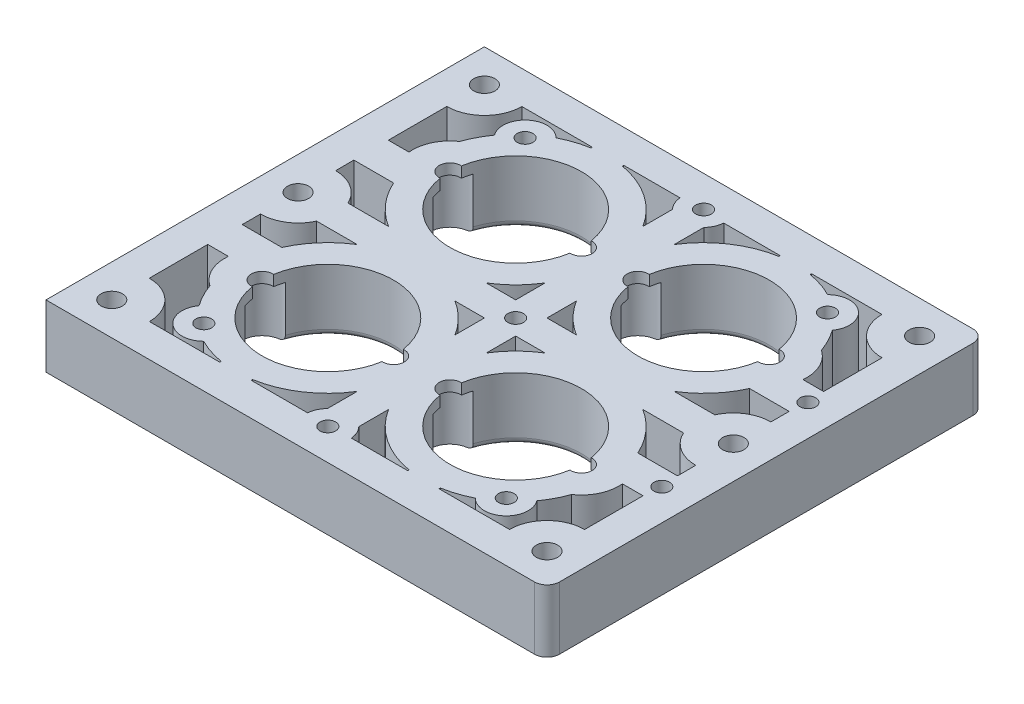
from build123d import *

# Parameters (mm, degrees)
SKETCH1_W                       = 80
SKETCH1_H                       = 70
BOSS_EXTRUDE1_DEPTH             = 10
CUT_EXTRUDE2_REACH              = 12
SKETCH3_R                       = 10.5
M3X0_5_TAPPED_HOLE1_D           = 2.5
M3X0_5_TAPPED_HOLE1_DEPTH       = 10
CBORE_FOR_M3_SHCS1_D            = 3.4
CBORE_FOR_M3_SHCS1_DEPTH        = 10
CBORE_FOR_M3_SHCS1_CBORE_D      = 6.5
CBORE_FOR_M3_SHCS1_CBORE_DEPTH  = 6
FILLET3_R                       = 1
TAP_DRILL_FOR_M3X0_5_TAP1_D     = 2.5
TAP_DRILL_FOR_M3X0_5_TAP1_DEPTH = 10
TAP_DRILL_FOR_M3X0_5_TAP1_TIP   = 0.751075774
FILLET4_R                       = 2
CBORE_FOR_M3_SHCS2_D            = 3.4
CBORE_FOR_M3_SHCS2_CBORE_D      = 6.5
CBORE_FOR_M3_SHCS2_CBORE_DEPTH  = 8.3
TAP_DRILL_FOR_M3X0_5_TAP2_D     = 2.5
TAP_DRILL_FOR_M3X0_5_TAP2_DEPTH = 10
CUT_EXTRUDE3_DEPTH              = 10


with BuildPart() as part:
    # Sketch1 → Boss-Extrude1 (new body)
    with BuildSketch(Plane(origin=(0, 0, 0), x_dir=(1, 0, 0), z_dir=(0, 1, 0))):
        with Locations((-2.631253278, 2.602774632)):
            Rectangle(SKETCH1_W, SKETCH1_H)
    extrude(amount=BOSS_EXTRUDE1_DEPTH)

    # Sketch3 → Cut-Extrude2 (cut, up to next)
    with BuildSketch(Plane(origin=(0, 10, 0), x_dir=(-1, 0, 0), z_dir=(0, 1, 0)), mode=Mode.PRIVATE) as cut_extrude2_sk1:
        with Locations(Location((17.631253278, -17.602774632, 0), (0, 0, 90))):  # turned: the seam where the file's is
            Circle(SKETCH3_R)
    cut_extrude2_tool1 = extrude(cut_extrude2_sk1.sketch, amount=-CUT_EXTRUDE2_REACH, mode=Mode.PRIVATE) & part.part
    add(cut_extrude2_tool1.solids().sort_by_distance((-17.631253, 10, -17.602775))[0], mode=Mode.SUBTRACT)
    # Sketch3 → Cut-Extrude2 (cut, up to next)
    with BuildSketch(Plane(origin=(0, 10, 0), x_dir=(-1, 0, 0), z_dir=(0, 1, 0)), mode=Mode.PRIVATE) as cut_extrude2_sk2:
        with Locations(Location((-12.368746722, -17.602774632, 0), (0, 0, 90))):  # turned: the seam where the file's is
            Circle(SKETCH3_R)
    cut_extrude2_tool2 = extrude(cut_extrude2_sk2.sketch, amount=-CUT_EXTRUDE2_REACH, mode=Mode.PRIVATE) & part.part
    add(cut_extrude2_tool2.solids().sort_by_distance((12.368747, 10, -17.602775))[0], mode=Mode.SUBTRACT)
    # Sketch3 → Cut-Extrude2 (cut, up to next)
    with BuildSketch(Plane(origin=(0, 10, 0), x_dir=(-1, 0, 0), z_dir=(0, 1, 0)), mode=Mode.PRIVATE) as cut_extrude2_sk3:
        with Locations(Location((17.631253278, 12.397225368, 0), (0, 0, 90))):  # turned: the seam where the file's is
            Circle(SKETCH3_R)
    cut_extrude2_tool3 = extrude(cut_extrude2_sk3.sketch, amount=-CUT_EXTRUDE2_REACH, mode=Mode.PRIVATE) & part.part
    add(cut_extrude2_tool3.solids().sort_by_distance((-17.631253, 10, 12.397225))[0], mode=Mode.SUBTRACT)
    # Sketch3 → Cut-Extrude2 (cut, up to next)
    with BuildSketch(Plane(origin=(0, 10, 0), x_dir=(-1, 0, 0), z_dir=(0, 1, 0)), mode=Mode.PRIVATE) as cut_extrude2_sk4:
        with Locations(Location((-12.368746722, 12.397225368, 0), (0, 0, 90))):  # turned: the seam where the file's is
            Circle(SKETCH3_R)
    cut_extrude2_tool4 = extrude(cut_extrude2_sk4.sketch, amount=-CUT_EXTRUDE2_REACH, mode=Mode.PRIVATE) & part.part
    add(cut_extrude2_tool4.solids().sort_by_distance((12.368747, 10, 12.397225))[0], mode=Mode.SUBTRACT)

    # M3x0.5 Tapped Hole1
    with Locations(Plane(origin=(-26.781253278, 10, 23.047225368), x_dir=(0, 0, 1), z_dir=(0, 1, 0))):
        with Locations((0, 0), (-51.3, 0), (-51.3, 48.3), (0, 48.3)):
            Hole(M3X0_5_TAPPED_HOLE1_D / 2, depth=M3X0_5_TAPPED_HOLE1_DEPTH)

    # CBORE for M3 SHCS1
    with Locations(Plane(origin=(-37.381253278, 0, 27.147225368), x_dir=(0, 0, -1), z_dir=(0, -1, 0))):
        with Locations((0, 0), (29.75, 0), (59.5, 0), (0, 69.5), (29.75, 69.5), (59.5, 69.5)):
            CounterBoreHole(CBORE_FOR_M3_SHCS1_D / 2, CBORE_FOR_M3_SHCS1_CBORE_D / 2, CBORE_FOR_M3_SHCS1_CBORE_DEPTH, depth=CBORE_FOR_M3_SHCS1_DEPTH)

    # Fillet3
    fillet3_edges = [part.edges().sort_by_distance(p)[0] for p in [
        (-17.631253278, 0, -28.102774632),
        (12.368746722, 0, -28.102774632),
        (-17.631253278, 0, 1.897225368),
        (12.368746722, 0, 1.897225368),
    ]]
    fillet(fillet3_edges, radius=FILLET3_R)

    # Tap Drill for M3x0.5 Tap1
    with Locations(Plane(origin=(-42.631253278, 5, 9.063892035), x_dir=(0, 0, -1), z_dir=(-1, 0, 0))):
        with Locations((0, 0), (23.333333334, 0)):
            Hole(TAP_DRILL_FOR_M3X0_5_TAP1_D / 2, depth=TAP_DRILL_FOR_M3X0_5_TAP1_DEPTH)
            with Locations((0, 0, -(TAP_DRILL_FOR_M3X0_5_TAP1_DEPTH + TAP_DRILL_FOR_M3X0_5_TAP1_TIP / 2))):  # 118° drill point
                Cone(0, TAP_DRILL_FOR_M3X0_5_TAP1_D / 2, TAP_DRILL_FOR_M3X0_5_TAP1_TIP, mode=Mode.SUBTRACT)

    # Fillet4
    fillet4_edges = [part.edges().sort_by_distance(p)[0] for p in [
        (37.368746722, 5, -37.602774632),
        (37.368746722, 5, 32.397225368),
    ]]
    fillet(fillet4_edges, radius=FILLET4_R)

    # CBORE for M3 SHCS2 (through all)
    with Locations(Plane(origin=(-28.131253278, 0, 12.397225368), x_dir=(0, 0, -1), z_dir=(0, -1, 0))):
        with Locations((0, 0), (0, 30), (0, 21), (0, 51), (30, 0), (30, 21), (30, 30), (30, 51)):
            CounterBoreHole(CBORE_FOR_M3_SHCS2_D / 2, CBORE_FOR_M3_SHCS2_CBORE_D / 2, CBORE_FOR_M3_SHCS2_CBORE_DEPTH)

    # Tap Drill for M3x0.5 Tap2
    with Locations(Plane(origin=(-2.631253278, 0, 27.397225368), x_dir=(0, 0, -1), z_dir=(0, -1, 0))):
        with Locations((0, 0), (30, 0), (60, 0), (41.666666667, 35), (18.333333333, 35)):
            Hole(TAP_DRILL_FOR_M3X0_5_TAP2_D / 2, depth=TAP_DRILL_FOR_M3X0_5_TAP2_DEPTH)

    # Sketch21 → Cut-Extrude3 (cut)
    with BuildSketch(Plane.XZ):
        with BuildLine():
            Line((-20.131253278, 27.133547896), (-31.381268867, 27.133547896))
            ThreePointArc((-31.381268867, 27.133547896), (-33.145530443, 22.89767809), (-37.387126516, 21.147228243))
            Line((-37.387126516, 21.147228243), (-37.387126516, 11.813892035))
            Line((-37.387126516, 11.813892035), (-34.091707756, 11.813892035))
            ThreePointArc((-34.091707756, 11.813892035), (-33.558684155, 14.929080308), (-31.514201196, 17.339184367))
            ThreePointArc((-31.514201196, 17.339184367), (-30.688791614, 19.22803017), (-29.607892074, 20.983221221))
            ThreePointArc((-29.607892074, 20.983221221), (-29.06210081, 25.701982332), (-24.314970793, 25.530660631))
            ThreePointArc((-24.314970793, 25.530660631), (-23.145728323, 26.062867198), (-21.934576811, 26.491217287))
            ThreePointArc((-21.934576811, 26.491217287), (-21.039662479, 26.733959597), (-20.131253278, 26.91993867))
            Line((-20.131253278, 26.91993867), (-20.131253278, 27.133547896))
        make_face()
        with BuildLine():
            Line((-15.131253278, 27.133547896), (-15.131253278, 26.91993867))
            ThreePointArc((-15.131253278, 26.91993867), (-9.413357154, 24.629370926), (-5.131253278, 20.20166011))
            Line((-5.131253278, 20.20166011), (-5.131253278, 24.947735625))
            ThreePointArc((-5.131253278, 24.947735625), (-5.819454868, 25.95314413), (-6.121306886, 27.133547896))
            Line((-6.121306886, 27.133547896), (-15.131253278, 27.133547896))
        make_face()
        with BuildLine():
            ThreePointArc((-31.053334234, 6.313892035), (-28.71884296, 2.690291934), (-25.43568802, -0.102774632))
            Line((-25.43568802, -0.102774632), (-31.92689722, -0.102774632))
            ThreePointArc((-31.92689722, -0.102774632), (-34.140882929, 2.446977837), (-37.381253278, 3.397225368))
            Line((-37.381253278, 3.397225368), (-37.387126516, 6.313892035))
            Line((-37.387126516, 6.313892035), (-31.053334234, 6.313892035))
        make_face()
        with BuildLine():
            Line((-31.92689722, -5.102774632), (-25.43568802, -5.102774632))
            ThreePointArc((-25.43568802, -5.102774632), (-28.71884296, -7.895841198), (-31.053334234, -11.519441299))
            Line((-31.053334234, -11.519441299), (-37.387126516, -11.519441299))
            Line((-37.387126516, -11.519441299), (-37.381253278, -8.602774632))
            ThreePointArc((-37.381253278, -8.602774632), (-34.140882929, -7.652527101), (-31.92689722, -5.102774632))
        make_face()
        with BuildLine():
            Line((-37.387126516, -26.352777507), (-37.387126516, -17.019441299))
            Line((-37.387126516, -17.019441299), (-34.091707756, -17.019441299))
            ThreePointArc((-34.091707756, -17.019441299), (-33.558684155, -20.134629572), (-31.514201196, -22.544733631))
            ThreePointArc((-31.514201196, -22.544733631), (-30.688791614, -24.433579434), (-29.607892074, -26.188770485))
            ThreePointArc((-29.607892074, -26.188770485), (-29.06210081, -30.907531595), (-24.314970793, -30.736209895))
            ThreePointArc((-24.314970793, -30.736209895), (-22.275356013, -31.588178145), (-20.131253278, -32.125487934))
            Line((-20.131253278, -32.125487934), (-20.131253278, -32.33909716))
            Line((-20.131253278, -32.33909716), (-31.381268867, -32.33909716))
            ThreePointArc((-31.381268867, -32.33909716), (-33.145530443, -28.103227354), (-37.387126516, -26.352777507))
        make_face()
        with BuildLine():
            Line((-15.131253278, -32.33909716), (-6.121306886, -32.33909716))
            ThreePointArc((-6.121306886, -32.33909716), (-5.819454868, -31.158693394), (-5.131253278, -30.153284889))
            Line((-5.131253278, -30.153284889), (-5.131253278, -25.407209374))
            ThreePointArc((-5.131253278, -25.407209374), (-9.413357154, -29.834920189), (-15.131253278, -32.125487934))
            Line((-15.131253278, -32.125487934), (-15.131253278, -32.33909716))
        make_face()
        with BuildLine():
            Line((-9.826818536, -5.102774632), (-5.131253278, -5.102774632))
            Line((-5.131253278, -5.102774632), (-5.131253278, -9.79833989))
            ThreePointArc((-5.131253278, -9.79833989), (-7.211099689, -7.182621043), (-9.826818536, -5.102774632))
        make_face()
        with BuildLine():
            ThreePointArc((-9.826818536, -0.102774632), (-7.211099689, 1.977071779), (-5.131253278, 4.592790626))
            Line((-5.131253278, 4.592790626), (-5.131253278, -0.102774632))
            Line((-5.131253278, -0.102774632), (-9.826818536, -0.102774632))
        make_face()
        with BuildLine():
            Line((4.56431198, -0.102774632), (-0.131253278, -0.102774632))
            Line((-0.131253278, -0.102774632), (-0.131253278, 4.592790626))
            ThreePointArc((-0.131253278, 4.592790626), (1.948593133, 1.977071779), (4.56431198, -0.102774632))
        make_face()
        with BuildLine():
            ThreePointArc((4.56431198, -5.102774632), (1.948593133, -7.182621043), (-0.131253278, -9.79833989))
            Line((-0.131253278, -9.79833989), (-0.131253278, -5.102774632))
            Line((-0.131253278, -5.102774632), (4.56431198, -5.102774632))
        make_face()
        with BuildLine():
            Line((9.868746722, -32.33909716), (9.868746722, -32.125487934))
            ThreePointArc((9.868746722, -32.125487934), (4.150850598, -29.834920189), (-0.131253278, -25.407209374))
            Line((-0.131253278, -25.407209374), (-0.131253278, -30.153284889))
            ThreePointArc((-0.131253278, -30.153284889), (0.556948312, -31.158693394), (0.858800331, -32.33909716))
            Line((0.858800331, -32.33909716), (9.868746722, -32.33909716))
        make_face()
        with BuildLine():
            Line((14.868746722, -32.33909716), (26.118762312, -32.33909716))
            ThreePointArc((26.118762312, -32.33909716), (27.883023887, -28.103227354), (32.124619961, -26.352777507))
            Line((32.124619961, -26.352777507), (32.124619961, -17.019441299))
            Line((32.124619961, -17.019441299), (28.8292012, -17.019441299))
            ThreePointArc((28.8292012, -17.019441299), (28.296177599, -20.134629572), (26.25169464, -22.544733631))
            ThreePointArc((26.25169464, -22.544733631), (25.426285059, -24.433579434), (24.345385518, -26.188770485))
            ThreePointArc((24.345385518, -26.188770485), (23.799594254, -30.907531595), (19.052464238, -30.736209895))
            ThreePointArc((19.052464238, -30.736209895), (17.883221767, -31.268416462), (16.672070255, -31.696766551))
            ThreePointArc((16.672070255, -31.696766551), (15.777155923, -31.939508861), (14.868746722, -32.125487934))
            Line((14.868746722, -32.125487934), (14.868746722, -32.33909716))
        make_face()
        with BuildLine():
            ThreePointArc((25.790827679, -11.519441299), (23.456336404, -7.895841198), (20.173181464, -5.102774632))
            Line((20.173181464, -5.102774632), (26.664390665, -5.102774632))
            ThreePointArc((26.664390665, -5.102774632), (28.878376373, -7.652527101), (32.118746722, -8.602774632))
            Line((32.118746722, -8.602774632), (32.124619961, -11.519441299))
            Line((32.124619961, -11.519441299), (25.790827679, -11.519441299))
        make_face()
        with BuildLine():
            Line((26.664390665, -0.102774632), (20.173181464, -0.102774632))
            ThreePointArc((20.173181464, -0.102774632), (23.456336404, 2.690291934), (25.790827679, 6.313892035))
            Line((25.790827679, 6.313892035), (32.124619961, 6.313892035))
            Line((32.124619961, 6.313892035), (32.118746722, 3.397225368))
            ThreePointArc((32.118746722, 3.397225368), (28.878376373, 2.446977837), (26.664390665, -0.102774632))
        make_face()
        with BuildLine():
            Line((32.124619961, 21.147228243), (32.124619961, 11.813892035))
            Line((32.124619961, 11.813892035), (28.8292012, 11.813892035))
            ThreePointArc((28.8292012, 11.813892035), (28.296177599, 14.929080308), (26.25169464, 17.339184367))
            ThreePointArc((26.25169464, 17.339184367), (25.426285059, 19.22803017), (24.345385518, 20.983221221))
            ThreePointArc((24.345385518, 20.983221221), (23.799594254, 25.701982332), (19.052464238, 25.530660631))
            ThreePointArc((19.052464238, 25.530660631), (17.012849458, 26.382628881), (14.868746722, 26.91993867))
            Line((14.868746722, 26.91993867), (14.868746722, 27.133547896))
            Line((14.868746722, 27.133547896), (26.118762312, 27.133547896))
            ThreePointArc((26.118762312, 27.133547896), (27.883023887, 22.89767809), (32.124619961, 21.147228243))
        make_face()
        with BuildLine():
            Line((9.868746722, 27.133547896), (0.858800331, 27.133547896))
            ThreePointArc((0.858800331, 27.133547896), (0.556948312, 25.95314413), (-0.131253278, 24.947735625))
            Line((-0.131253278, 24.947735625), (-0.131253278, 20.20166011))
            ThreePointArc((-0.131253278, 20.20166011), (4.150850598, 24.629370926), (9.868746722, 26.91993867))
            Line((9.868746722, 26.91993867), (9.868746722, 27.133547896))
        make_face()
    extrude(amount=-CUT_EXTRUDE3_DEPTH, mode=Mode.SUBTRACT)


solid = part.part
